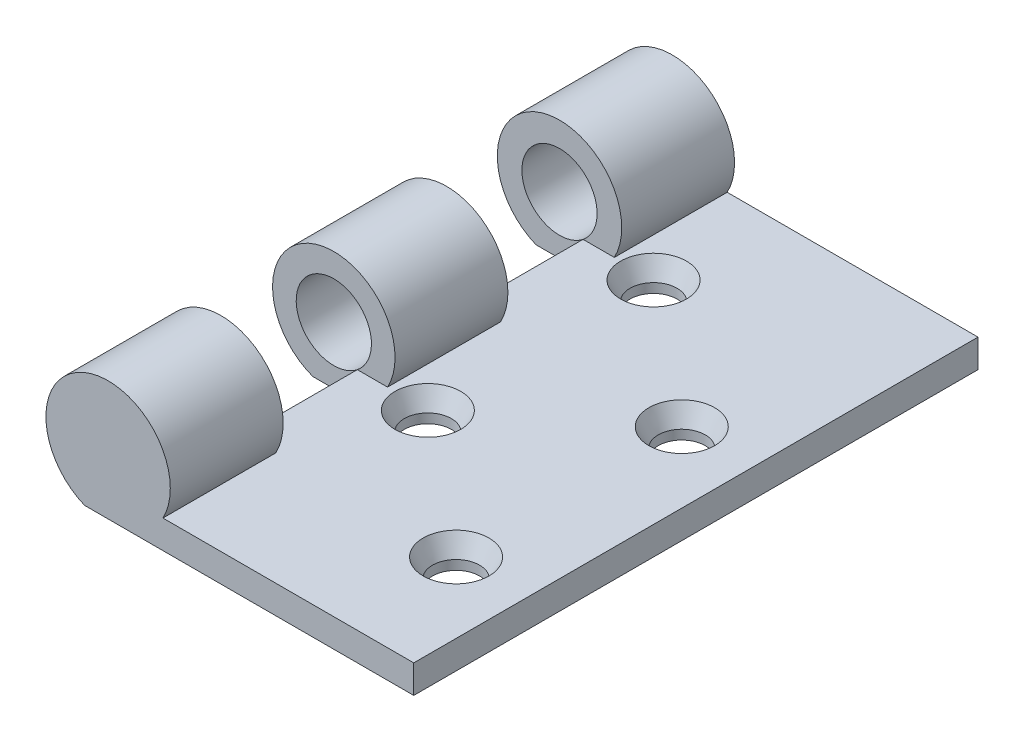
from build123d import *

# Parameters (mm, degrees)
SKETCH1_W           = 30
SKETCH1_H           = 60
BOSS_EXTRUDE1_DEPTH = 3
SKETCH2_R           = 4
BOSS_EXTRUDE2_DEPTH = 12
SKETCH3_R           = 4
BOSS_EXTRUDE3_DEPTH = 6
SKETCH8_R           = 2.5
CUT_EXTRUDE1_DEPTH  = 4
CHAMFER1_SIZE       = 1
CHAMFER1_SIZE2      = 2
SKETCH9_R           = 4
BOSS_EXTRUDE4_DEPTH = 2


with BuildPart() as part:
    # Sketch1 → Boss-Extrude1 (new body)
    with BuildSketch(Plane(origin=(0, 0, 0), x_dir=(1, 0, 0), z_dir=(0, 1, 0))):
        Rectangle(SKETCH1_W, SKETCH1_H)
    extrude(amount=BOSS_EXTRUDE1_DEPTH)

    # Sketch2 → Boss-Extrude2 (add)
    with BuildSketch(Plane.XY.offset(30)):
        with BuildLine():
            Line((-15, 0), (-20, 0))
            ThreePointArc((-20, 0), (-17.5, 12.735742832), (-15, 0))
        make_face()
        with Locations((-17.5, 6.122498999)):
            Circle(SKETCH2_R, mode=Mode.SUBTRACT)
    boss_extrude2 = extrude(amount=-BOSS_EXTRUDE2_DEPTH)

    # Mirror1: Boss-Extrude2 across plane
    add(boss_extrude2.mirror(Plane.XY))

    # Sketch3 → Boss-Extrude3 (add, symmetric)
    with BuildSketch(Plane.XY):
        with BuildLine():
            Line((-19.72149558, 0), (-15.27850442, 0))
            ThreePointArc((-15.27850442, 0), (-17.5, 12.635565605), (-19.72149558, 0))
        make_face()
        with Locations((-17.5, 6.122498999)):
            Circle(SKETCH3_R, mode=Mode.SUBTRACT)
    extrude(amount=BOSS_EXTRUDE3_DEPTH, both=True)

    # Sketch8 → Cut-Extrude1 (cut, through all)
    with BuildSketch(Plane(origin=(0, 3, 0), x_dir=(1, 0, 0), z_dir=(0, 1, 0))):
        with Locations((7.5, -18)):
            Circle(SKETCH8_R)
        with Locations((-7.5, -6)):
            Circle(SKETCH8_R)
        with Locations((7.5, 6)):
            Circle(SKETCH8_R)
        with Locations((-7.5, 18)):
            Circle(SKETCH8_R)
    extrude(amount=-CUT_EXTRUDE1_DEPTH, mode=Mode.SUBTRACT)

    # Chamfer1
    chamfer1_edges = [part.edges().sort_by_distance(p)[0] for p in [
        (-10, 3, -18),
        (-10, 3, 6),
        (5, 3, 18),
        (5, 3, -6),
    ]]
    chamfer1_side = [part.faces().sort_by_distance(p)[0] for p in [
        (0.987193721, 3, 0),
    ]]
    chamfer(chamfer1_edges, length=CHAMFER1_SIZE, length2=CHAMFER1_SIZE2, reference=chamfer1_side[0])

    # Sketch9 → Boss-Extrude4 (add)
    with BuildSketch(Plane.XY.offset(30)):
        with Locations((-17.5, 6.122498999)):
            Circle(SKETCH9_R)
    extrude(amount=-BOSS_EXTRUDE4_DEPTH)


solid = part.part
